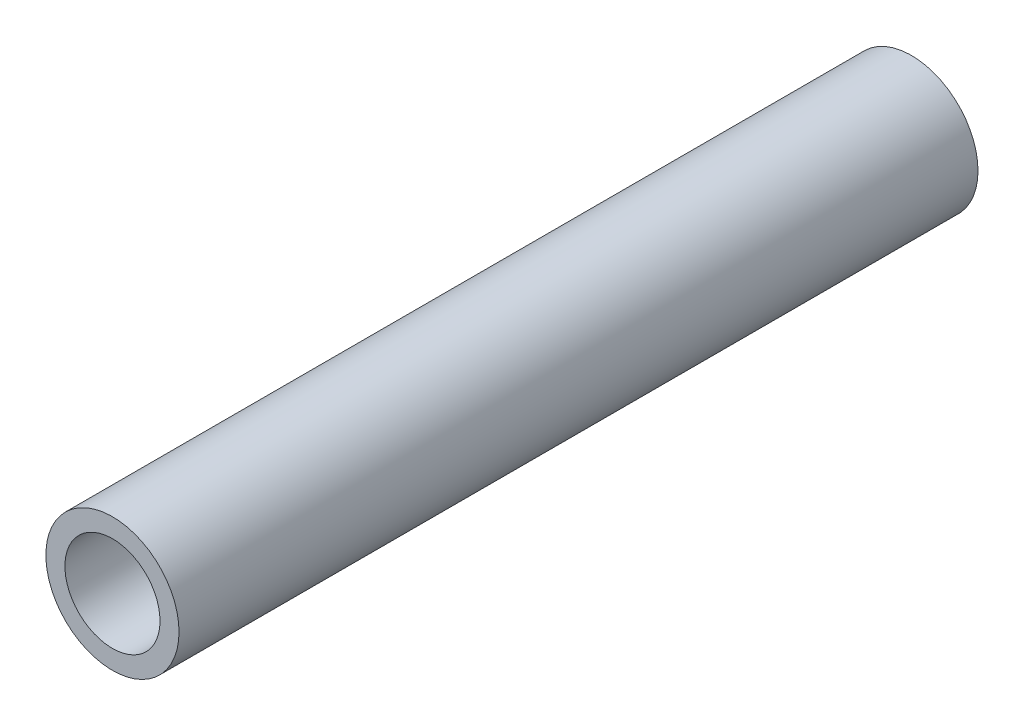
from build123d import *

# Parameters (mm, degrees)
SKETCH1_R           = 3.5
SKETCH1_R_2         = 2.5
BOSS_EXTRUDE1_DEPTH = 42


with BuildPart() as part:
    # Sketch1 → Boss-Extrude1 (new body)
    with BuildSketch(Plane.XY):
        Circle(SKETCH1_R)
        Circle(SKETCH1_R_2, mode=Mode.SUBTRACT)
    extrude(amount=BOSS_EXTRUDE1_DEPTH)


solid = part.part
